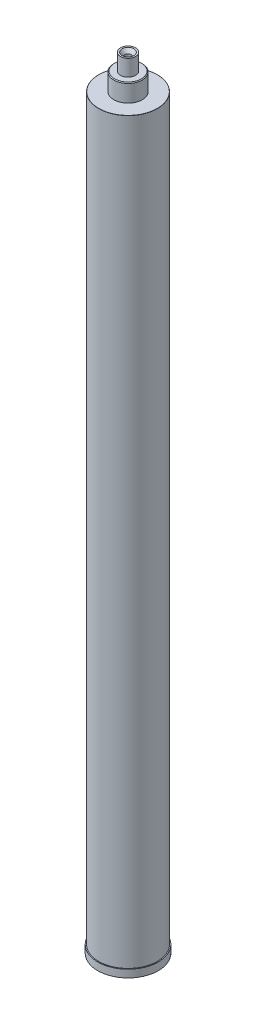
from build123d import *

# Parameters (mm, degrees)
SKETCH1_R                                           = 49.2125
BOSS_EXTRUDE1_DEPTH                                 = 1238.504
SKETCH3_R                                           = 50.8
BOSS_EXTRUDE2_DEPTH                                 = 12.7
CHAMFER1_SIZE                                       = 1.27
FILLET1_R                                           = 0.254
CSK_FOR_3_8_FLAT_HEAD_SOCKET_CAP_SCREW1_D           = 9.8044
CSK_FOR_3_8_FLAT_HEAD_SOCKET_CAP_SCREW1_DEPTH       = 25.4
CSK_FOR_3_8_FLAT_HEAD_SOCKET_CAP_SCREW1_CSINK_D     = 19.8374
CSK_FOR_3_8_FLAT_HEAD_SOCKET_CAP_SCREW1_CSINK_ANGLE = 82
CSK_FOR_3_8_FLAT_HEAD_SOCKET_CAP_SCREW1_TIP         = 2.945538927


with BuildPart() as part:
    # Sketch1 → Boss-Extrude1 (new body)
    with BuildSketch(Plane(origin=(0, 0, 0), x_dir=(1, 0, 0), z_dir=(0, 1, 0))):
        Circle(SKETCH1_R)
    extrude(amount=BOSS_EXTRUDE1_DEPTH)

    # Sketch2 → Revolve1 (revolve)
    with BuildSketch(Plane.XY):
        Polygon((0, 1238.504), (0, 1295.654), (12.7, 1295.654), (12.7, 1268.349), (23.876, 1268.349), (23.876, 1238.504), align=None)
    revolve(axis=Axis((0, 1238.504, 0), (0, 1, 0)))

    # Sketch3 → Boss-Extrude2 (add)
    with BuildSketch(Plane.XZ):
        Circle(SKETCH3_R)
    extrude(amount=BOSS_EXTRUDE2_DEPTH)

    # Chamfer1
    chamfer1_edges = [part.edges().sort_by_distance(p)[0] for p in [
        (-23.876, 1268.349, 0),
    ]]
    chamfer(chamfer1_edges, length=CHAMFER1_SIZE)

    # Fillet1
    fillet1_edges = [part.edges().sort_by_distance(p)[0] for p in [
        (-49.2125, 1238.504, 0),
    ]]
    fillet(fillet1_edges, radius=FILLET1_R)

    # CSK for 3/8 Flat Head Socket Cap Screw1
    with Locations(Plane(origin=(0, 1295.654, 0), x_dir=(1, 0, 0), z_dir=(0, 1, 0))):
        with Locations((0, 0)):
            CounterSinkHole(CSK_FOR_3_8_FLAT_HEAD_SOCKET_CAP_SCREW1_D / 2, CSK_FOR_3_8_FLAT_HEAD_SOCKET_CAP_SCREW1_CSINK_D / 2, depth=CSK_FOR_3_8_FLAT_HEAD_SOCKET_CAP_SCREW1_DEPTH, counter_sink_angle=CSK_FOR_3_8_FLAT_HEAD_SOCKET_CAP_SCREW1_CSINK_ANGLE)
            with Locations((0, 0, -(CSK_FOR_3_8_FLAT_HEAD_SOCKET_CAP_SCREW1_DEPTH + CSK_FOR_3_8_FLAT_HEAD_SOCKET_CAP_SCREW1_TIP / 2))):  # 118° drill point
                Cone(0, CSK_FOR_3_8_FLAT_HEAD_SOCKET_CAP_SCREW1_D / 2, CSK_FOR_3_8_FLAT_HEAD_SOCKET_CAP_SCREW1_TIP, mode=Mode.SUBTRACT)


solid = part.part
